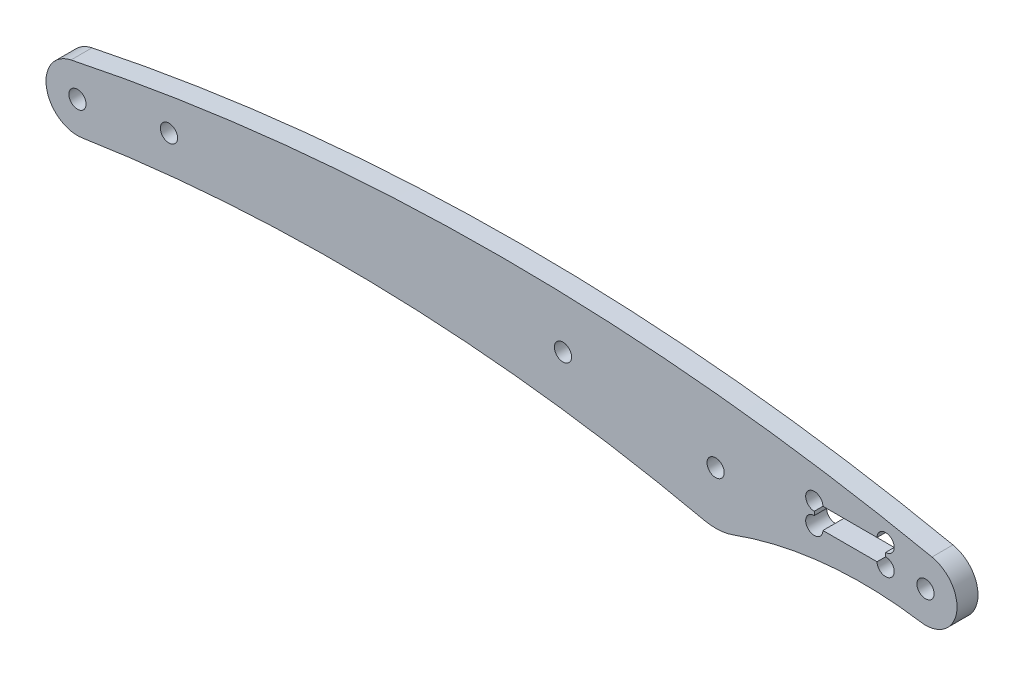
from build123d import *

# Parameters (mm, degrees)
SCHIZZO1_R                   = 2.05
ESTRUSIONE_ESTRUSIONE1_DEPTH = 5
SCHIZZO2_R                   = 2.05
TAGLIO_ESTRUSIONE1_DEPTH     = 10
CUT_EXTRUDE1_REACH           = 7
SKETCH1_W                    = 17
SKETCH1_H                    = 5
CUT_EXTRUDE2_REACH           = 7
SKETCH2_R                    = 2.05


with BuildPart() as part:
    # Schizzo1 → Estrusione-Estrusione1 (new body)
    with BuildSketch(Plane.XY):
        with BuildLine():
            ThreePointArc((-1.538071066, 7.340595166), (-7.378454008, -1.344773756), (1.150548918, -7.411223731))
            ThreePointArc((1.150548918, -7.411223731), (75.443261143, -2.885528453), (149.288277512, -12.20231786))
            ThreePointArc((149.288277512, -12.20231786), (152.810661847, -12.473685396), (156.268292683, -11.748688334))
            ThreePointArc((156.268292683, -11.748688334), (178.283063002, -6.762377854), (200.846153846, -7.410711103))
            ThreePointArc((200.846153846, -7.410711103), (209.378154672, -1.346415107), (203.538071066, 7.340595166))
            ThreePointArc((203.538071066, 7.340595166), (101, 17.967584078), (-1.538071066, 7.340595166))
        make_face()
        Circle(SCHIZZO1_R, mode=Mode.SUBTRACT)
        with Locations((202, 0)):
            Circle(SCHIZZO1_R, mode=Mode.SUBTRACT)
        with Locations((152, 0)):
            Circle(SCHIZZO1_R, mode=Mode.SUBTRACT)
    extrude(amount=ESTRUSIONE_ESTRUSIONE1_DEPTH)

    # Schizzo2 → Taglio-Estrusione1 (cut)
    with BuildSketch(Plane.XY.offset(5)):
        with Locations((21.792647349, 3.923925867)):
            Circle(SCHIZZO2_R)
        with Locations((115.643522851, 5.673925867)):
            Circle(SCHIZZO2_R)
    extrude(amount=-TAGLIO_ESTRUSIONE1_DEPTH, mode=Mode.SUBTRACT)

    # Sketch1 → Cut-Extrude1 (cut, up to next)
    with BuildSketch(Plane.XY.offset(5), mode=Mode.PRIVATE) as cut_extrude1_sk1:
        with Locations((184, 2.320601078)):
            Rectangle(SKETCH1_W, SKETCH1_H)
    cut_extrude1_tool1 = extrude(cut_extrude1_sk1.sketch, amount=-CUT_EXTRUDE1_REACH, mode=Mode.PRIVATE) & part.part
    add(cut_extrude1_tool1.solids().sort_by_distance((184, 2.320601, 5))[0], mode=Mode.SUBTRACT)

    # Sketch2 → Cut-Extrude2 (cut, up to next)
    with BuildSketch(Plane.XY.offset(5), mode=Mode.PRIVATE) as cut_extrude2_sk1:
        with Locations((175.5, 4.820601078)):
            Circle(SKETCH2_R)
    cut_extrude2_tool1 = extrude(cut_extrude2_sk1.sketch, amount=-CUT_EXTRUDE2_REACH, mode=Mode.PRIVATE) & part.part
    add(cut_extrude2_tool1.solids().sort_by_distance((175.5, 4.820601, 5))[0], mode=Mode.SUBTRACT)
    # Sketch2 → Cut-Extrude2 (cut, up to next)
    with BuildSketch(Plane.XY.offset(5), mode=Mode.PRIVATE) as cut_extrude2_sk2:
        with Locations((175.5, -0.179398922)):
            Circle(SKETCH2_R)
    cut_extrude2_tool2 = extrude(cut_extrude2_sk2.sketch, amount=-CUT_EXTRUDE2_REACH, mode=Mode.PRIVATE) & part.part
    add(cut_extrude2_tool2.solids().sort_by_distance((175.5, -0.179399, 5))[0], mode=Mode.SUBTRACT)
    # Sketch2 → Cut-Extrude2 (cut, up to next)
    with BuildSketch(Plane.XY.offset(5), mode=Mode.PRIVATE) as cut_extrude2_sk3:
        with Locations((192.5, -0.179398922)):
            Circle(SKETCH2_R)
    cut_extrude2_tool3 = extrude(cut_extrude2_sk3.sketch, amount=-CUT_EXTRUDE2_REACH, mode=Mode.PRIVATE) & part.part
    add(cut_extrude2_tool3.solids().sort_by_distance((192.5, -0.179399, 5))[0], mode=Mode.SUBTRACT)
    # Sketch2 → Cut-Extrude2 (cut, up to next)
    with BuildSketch(Plane.XY.offset(5), mode=Mode.PRIVATE) as cut_extrude2_sk4:
        with Locations((192.5, 4.820601078)):
            Circle(SKETCH2_R)
    cut_extrude2_tool4 = extrude(cut_extrude2_sk4.sketch, amount=-CUT_EXTRUDE2_REACH, mode=Mode.PRIVATE) & part.part
    add(cut_extrude2_tool4.solids().sort_by_distance((192.5, 4.820601, 5))[0], mode=Mode.SUBTRACT)


solid = part.part
